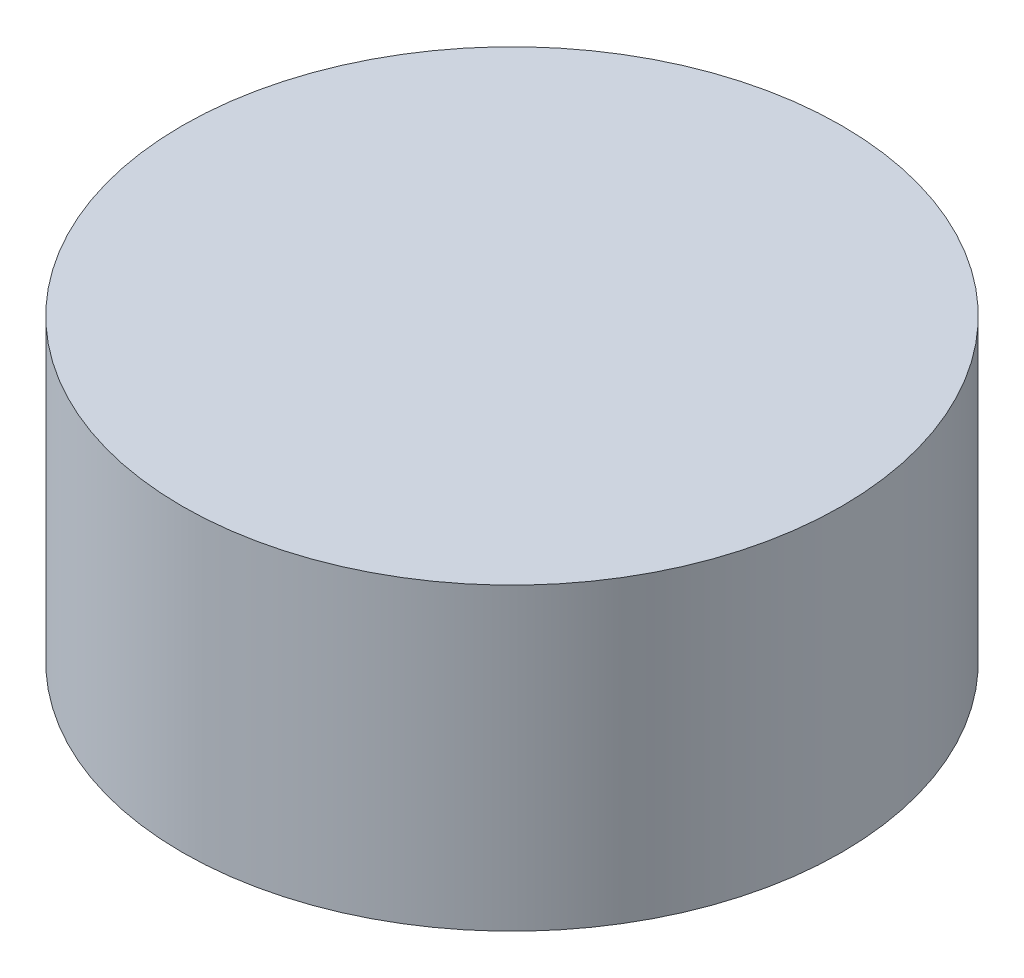
from build123d import *

# Parameters (mm, degrees)
SKETCH1_R           = 5.588
BOSS_EXTRUDE1_DEPTH = 5.08


with BuildPart() as part:
    # Sketch1 → Boss-Extrude1 (new body)
    with BuildSketch(Plane(origin=(0, 0, 0), x_dir=(1, 0, 0), z_dir=(0, 1, 0))):
        Circle(SKETCH1_R)
    extrude(amount=BOSS_EXTRUDE1_DEPTH)


solid = part.part
